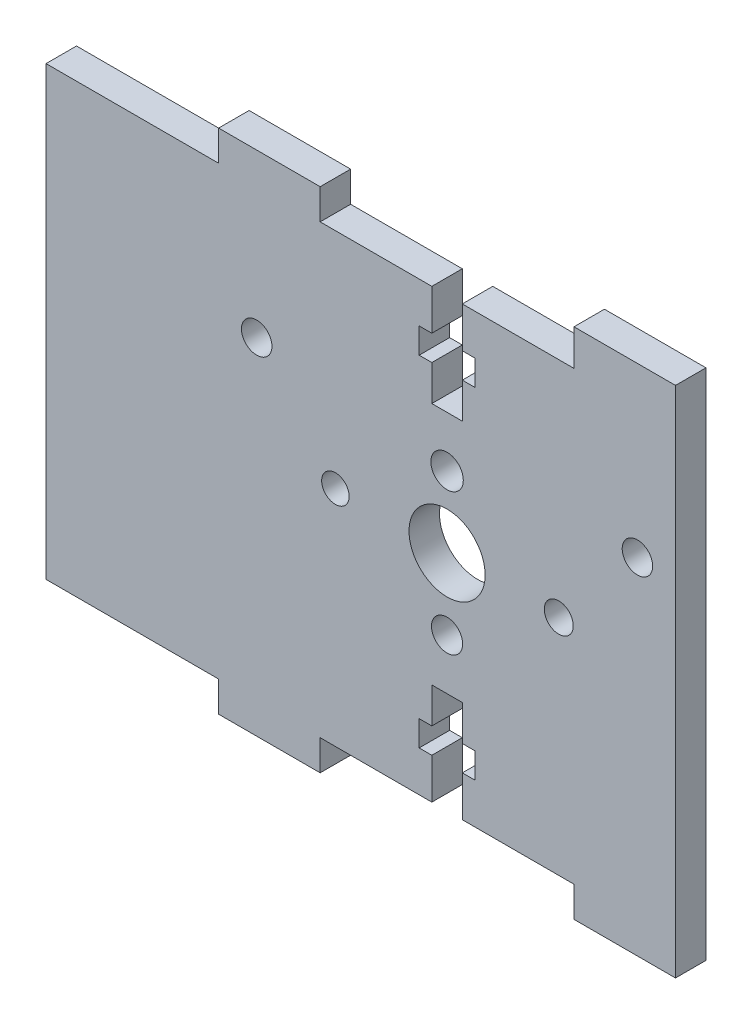
from build123d import *

# Parameters (mm, degrees)
MODEL_R             = 3.750000001
MODEL_R_2           = 1.500000002
MODEL_R_3           = 1.353150001
MODEL_R_4           = 1.598250001
MODEL_R_5           = 1.533250001
MODEL_R_6           = 1.426350001
BOSS_EXTRUDE1_DEPTH = 3


with BuildPart() as part:
    # Model → Boss-Extrude1 (new body)
    with BuildSketch(Plane.XY):
        Polygon((58.24, 47.9), (61.24, 47.9), (61.24, 51.4001), (62.49, 51.4001), (62.49, 53.9001), (61.24, 53.9001), (61.24, 57.9), (72.24, 57.9), (72.24, 61.449728443), (82.24, 61.449728443), (82.24, 57.9), (82.24, 13.9), (82.24, 10.9), (72.24, 10.9), (72.24, 13.9), (61.24, 13.9), (61.24, 17.9), (62.49, 17.9), (62.49, 20.4), (61.24, 20.4), (61.24, 23.9), (58.24, 23.9), (58.24, 20.4), (56.99, 20.4), (56.99, 17.9), (58.24, 17.9), (58.24, 13.9), (47.24, 13.9), (47.24, 10.9), (37.24, 10.9), (37.24, 13.9), (20.24, 13.9), (20.24, 57.9), (37.24, 57.9), (37.24, 60.9), (47.24, 60.9), (47.24, 57.9), (58.24, 57.9), (58.24, 53.9001), (56.99, 53.9001), (56.99, 51.4001), (58.24, 51.4001), align=None)
        with Locations((59.739999999, 35.899999999)):
            Circle(MODEL_R, mode=Mode.SUBTRACT)
        with Locations((40.989999998, 44.899999998)):
            Circle(MODEL_R_2, mode=Mode.SUBTRACT)
        with Locations((48.73995, 35.90005)):
            Circle(MODEL_R_3, mode=Mode.SUBTRACT)
        with Locations((59.73995, 42.90005)):
            Circle(MODEL_R_4, mode=Mode.SUBTRACT)
        with Locations((59.73995, 28.90005)):
            Circle(MODEL_R_5, mode=Mode.SUBTRACT)
        with Locations((70.73995, 35.90005)):
            Circle(MODEL_R_6, mode=Mode.SUBTRACT)
        with Locations((78.489999998, 44.899999998)):
            Circle(MODEL_R_2, mode=Mode.SUBTRACT)
    extrude(amount=BOSS_EXTRUDE1_DEPTH)


solid = part.part
